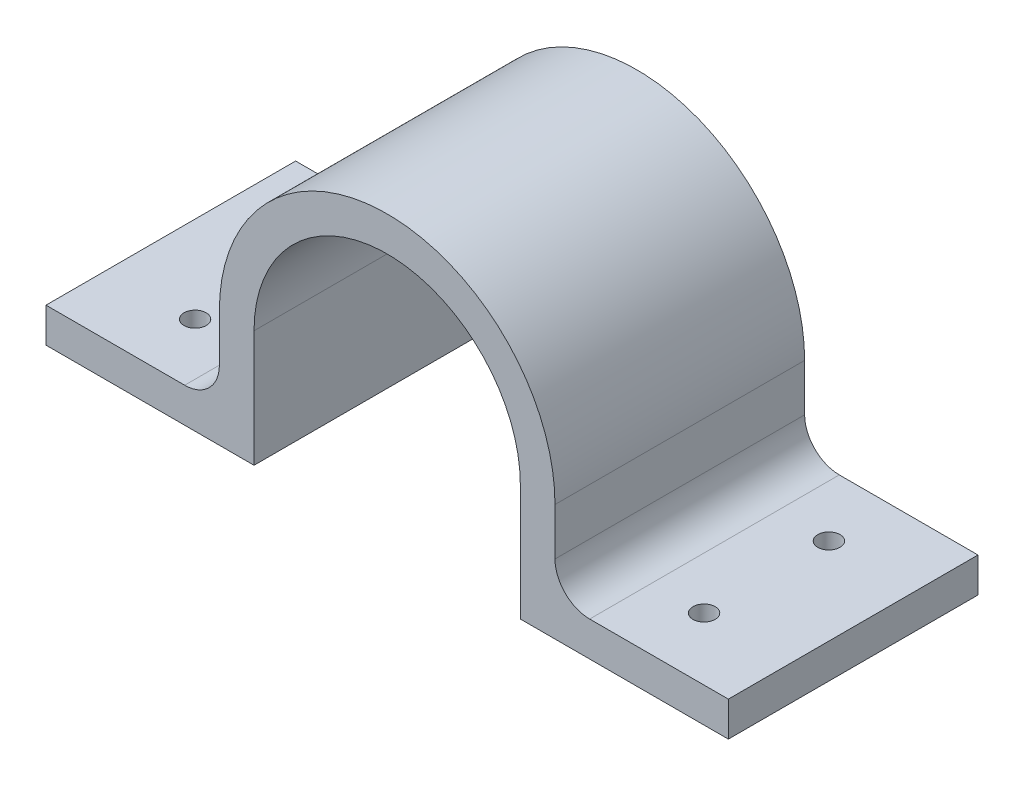
from build123d import *

# Parameters (mm, degrees)
BOSS_EXTRUDE1_DEPTH = 36
SKETCH2_R           = 1.6
CUT_EXTRUDE1_DEPTH  = 5
FILLET1_R           = 5


with BuildPart() as part:
    # Sketch1 → Boss-Extrude1 (new body)
    with BuildSketch(Plane.XY):
        with BuildLine():
            Line((-19.2, 0), (-19.2, -16.8))
            Line((-19.2, -16.8), (-49.2, -16.8))
            Line((-49.2, -16.8), (-49.2, -11.8))
            Line((-49.2, -11.8), (-24.2, -11.8))
            Line((-24.2, -11.8), (-24.2, 0))
            ThreePointArc((-24.2, 0), (0, 24.2), (24.2, 0))
            Line((24.2, 0), (24.2, -11.8))
            Line((24.2, -11.8), (49.2, -11.8))
            Line((49.2, -11.8), (49.2, -16.8))
            Line((49.2, -16.8), (19.2, -16.8))
            Line((19.2, -16.8), (19.2, 0))
            ThreePointArc((19.2, 0), (0, 19.2), (-19.2, 0))
        make_face()
    extrude(amount=-BOSS_EXTRUDE1_DEPTH)

    # Sketch2 → Cut-Extrude1 (cut)
    with BuildSketch(Plane(origin=(0, -11.8, 0), x_dir=(1, 0, 0), z_dir=(0, 1, 0))):
        with Locations((-36.7, 27)):
            Circle(SKETCH2_R)
        with Locations((-36.7, 9)):
            Circle(SKETCH2_R)
        with Locations((36.7, 27)):
            Circle(SKETCH2_R)
        with Locations((36.7, 9)):
            Circle(SKETCH2_R)
    extrude(amount=-CUT_EXTRUDE1_DEPTH, mode=Mode.SUBTRACT)

    # Fillet1
    fillet1_edges = [part.edges().sort_by_distance(p)[0] for p in [
        (24.2, -11.8, -18),
        (-24.2, -11.8, -18),
    ]]
    fillet(fillet1_edges, radius=FILLET1_R)


solid = part.part
